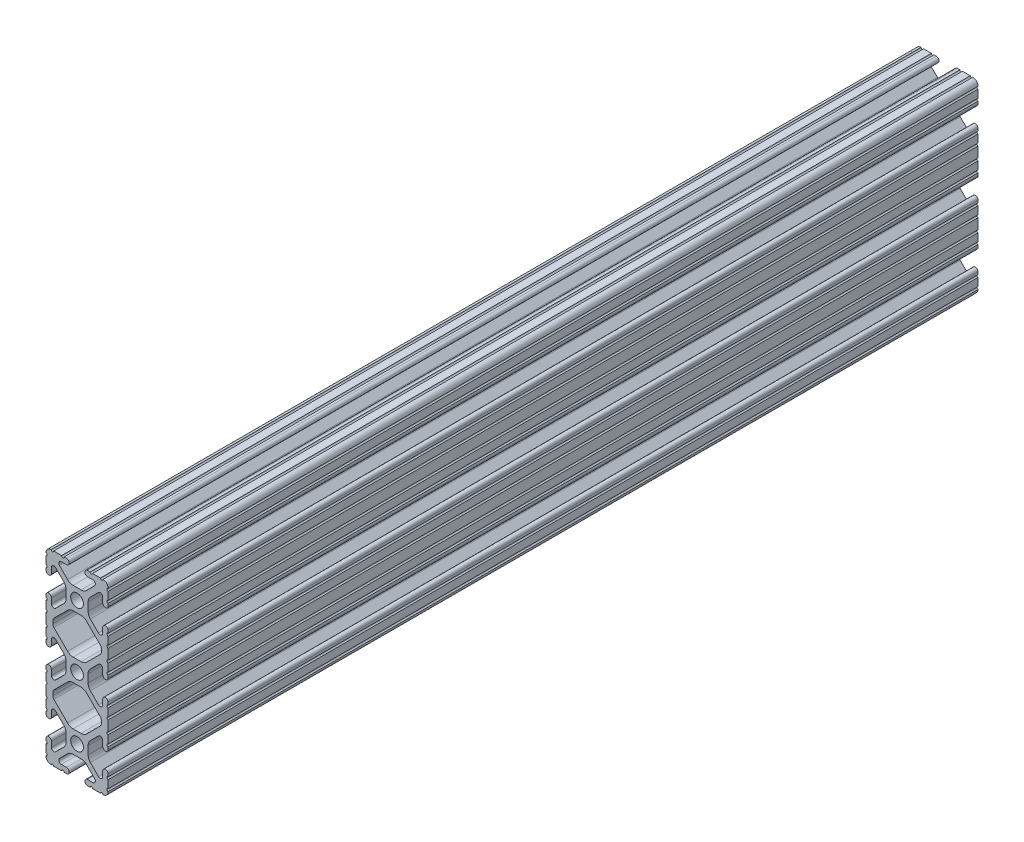
from build123d import *

# Parameters (mm, degrees)
SKETCH1_R           = 2.6035
BOSS_EXTRUDE1_DEPTH = 177.8


with BuildPart() as part:
    # Sketch1 → Boss-Extrude1 (new body, symmetric)
    with BuildSketch(Plane.XY):
        with BuildLine():
            Line((-12.7, 34.9504), (-12.7, 31.7246))
            ThreePointArc((-12.7, 31.7246), (-12.192, 31.2166), (-12.7, 30.7086))
            Line((-12.7, 30.7086), (-12.7, 29.702307889))
            ThreePointArc((-12.7, 29.702307889), (-11.5951, 28.597407889), (-10.4902, 29.702307889))
            Line((-10.4902, 29.702307889), (-10.4902, 31.874794456))
            ThreePointArc((-10.4902, 31.874794456), (-9.863006367, 32.813456061), (-8.75577951, 32.593214945))
            Line((-8.75577951, 32.593214945), (-5.43843597, 29.275871405))
            ThreePointArc((-5.43843597, 29.275871405), (-4.750182484, 28.245827272), (-4.5085, 27.030807374))
            Line((-4.5085, 27.030807374), (-4.5085, 23.769192626))
            ThreePointArc((-4.5085, 23.769192626), (-4.750182484, 22.554172728), (-5.43843597, 21.524128595))
            Line((-5.43843597, 21.524128595), (-8.75577951, 18.206785055))
            ThreePointArc((-8.75577951, 18.206785055), (-9.863006367, 17.986543939), (-10.4902, 18.925205544))
            Line((-10.4902, 18.925205544), (-10.4902, 21.097692111))
            ThreePointArc((-10.4902, 21.097692111), (-11.5951, 22.202592111), (-12.7, 21.097692111))
            Line((-12.7, 21.097692111), (-12.7, 20.0914))
            ThreePointArc((-12.7, 20.0914), (-12.192, 19.5834), (-12.7, 19.0754))
            Line((-12.7, 19.0754), (-12.7, 15.8496))
            ThreePointArc((-12.7, 15.8496), (-12.192, 15.3416), (-12.7, 14.8336))
            Line((-12.7, 14.8336), (-12.7, 10.5664))
            ThreePointArc((-12.7, 10.5664), (-12.192, 10.0584), (-12.7, 9.5504))
            Line((-12.7, 9.5504), (-12.7, 6.3246))
            ThreePointArc((-12.7, 6.3246), (-12.192000017, 5.8166), (-12.7, 5.3086))
            Line((-12.7, 5.3086), (-12.7, 4.302307889))
            ThreePointArc((-12.7, 4.302307889), (-11.5951, 3.197407889), (-10.4902, 4.302307889))
            Line((-10.4902, 4.302307889), (-10.4902, 6.474794456))
            ThreePointArc((-10.4902, 6.474794456), (-9.863006367, 7.413456061), (-8.75577951, 7.193214945))
            Line((-8.75577951, 7.193214945), (-5.43843597, 3.875871405))
            ThreePointArc((-5.43843597, 3.875871405), (-4.750182484, 2.845827272), (-4.5085, 1.630807374))
            Line((-4.5085, 1.630807374), (-4.5085, -1.630807374))
            ThreePointArc((-4.5085, -1.630807374), (-4.750182484, -2.845827272), (-5.43843597, -3.875871405))
            Line((-5.43843597, -3.875871405), (-8.75577951, -7.193214945))
            ThreePointArc((-8.75577951, -7.193214945), (-9.863006367, -7.413456061), (-10.4902, -6.474794456))
            Line((-10.4902, -6.474794456), (-10.4902, -4.302307889))
            ThreePointArc((-10.4902, -4.302307889), (-11.5951, -3.197407889), (-12.7, -4.302307889))
            Line((-12.7, -4.302307889), (-12.7, -5.3086))
            ThreePointArc((-12.7, -5.3086), (-12.191999983, -5.8166), (-12.7, -6.3246))
            Line((-12.7, -6.3246), (-12.7, -9.5504))
            ThreePointArc((-12.7, -9.5504), (-12.192, -10.0584), (-12.7, -10.5664))
            Line((-12.7, -10.5664), (-12.7, -14.8336))
            ThreePointArc((-12.7, -14.8336), (-12.192, -15.3416), (-12.7, -15.8496))
            Line((-12.7, -15.8496), (-12.7, -19.0754))
            ThreePointArc((-12.7, -19.0754), (-12.192, -19.5834), (-12.7, -20.0914))
            Line((-12.7, -20.0914), (-12.7, -21.097692111))
            ThreePointArc((-12.7, -21.097692111), (-11.5951, -22.202592111), (-10.4902, -21.097692111))
            Line((-10.4902, -21.097692111), (-10.4902, -18.925205544))
            ThreePointArc((-10.4902, -18.925205544), (-9.863006367, -17.986543939), (-8.75577951, -18.206785055))
            Line((-8.75577951, -18.206785055), (-5.43843597, -21.524128595))
            ThreePointArc((-5.43843597, -21.524128595), (-4.750182484, -22.554172728), (-4.5085, -23.769192626))
            Line((-4.5085, -23.769192626), (-4.5085, -27.030807374))
            ThreePointArc((-4.5085, -27.030807374), (-4.750182484, -28.245827272), (-5.43843597, -29.275871405))
            Line((-5.43843597, -29.275871405), (-8.75577951, -32.593214945))
            ThreePointArc((-8.75577951, -32.593214945), (-9.863006367, -32.813456061), (-10.4902, -31.874794456))
            Line((-10.4902, -31.874794456), (-10.4902, -29.702307889))
            ThreePointArc((-10.4902, -29.702307889), (-11.5951, -28.597407889), (-12.7, -29.702307889))
            Line((-12.7, -29.702307889), (-12.7, -30.7086))
            ThreePointArc((-12.7, -30.7086), (-12.192, -31.2166), (-12.7, -31.7246))
            Line((-12.7, -31.7246), (-12.7, -34.9504))
            ThreePointArc((-12.7, -34.9504), (-12.192, -35.4584), (-12.7, -35.9664))
            ThreePointArc((-12.7, -35.9664), (-12.082677406, -37.482677406), (-10.5664, -38.1))
            ThreePointArc((-10.5664, -38.1), (-10.0584, -37.592), (-9.5504, -38.1))
            Line((-9.5504, -38.1), (-6.3246, -38.1))
            ThreePointArc((-6.3246, -38.1), (-5.816599996, -37.592000017), (-5.3086, -38.100000008))
            Line((-5.3086, -38.100000008), (-4.302307889, -38.100000008))
            ThreePointArc((-4.302307889, -38.100000008), (-3.197407889, -36.995100008), (-4.302307889, -35.890200008))
            Line((-4.302307889, -35.890200008), (-6.474794456, -35.890200008))
            ThreePointArc((-6.474794456, -35.890200008), (-7.413456061, -35.263006376), (-7.193214945, -34.155779519))
            Line((-7.193214945, -34.155779519), (-3.875871405, -30.838435978))
            ThreePointArc((-3.875871405, -30.838435978), (-2.845827272, -30.150182493), (-1.630807374, -29.908500008))
            Line((-1.630807374, -29.908500008), (1.630807374, -29.908500008))
            ThreePointArc((1.630807374, -29.908500008), (2.845827272, -30.150182493), (3.875871405, -30.838435978))
            Line((3.875871405, -30.838435978), (7.193214945, -34.155779519))
            ThreePointArc((7.193214945, -34.155779519), (7.413456061, -35.263006376), (6.474794456, -35.890200008))
            Line((6.474794456, -35.890200008), (4.302307889, -35.890200008))
            ThreePointArc((4.302307889, -35.890200008), (3.197407889, -36.995100008), (4.302307889, -38.100000008))
            Line((4.302307889, -38.100000008), (5.3086, -38.100000008))
            ThreePointArc((5.3086, -38.100000008), (5.8166, -37.591999992), (6.3246, -38.100000008))
            Line((6.3246, -38.100000008), (9.5504, -38.100000008))
            ThreePointArc((9.5504, -38.100000008), (10.0584, -37.592000008), (10.5664, -38.100000008))
            ThreePointArc((10.5664, -38.100000008), (12.082677406, -37.482677414), (12.7, -35.966400008))
            ThreePointArc((12.7, -35.966400008), (12.192, -35.458400008), (12.7, -34.950400008))
            Line((12.7, -34.950400008), (12.7, -31.724600008))
            ThreePointArc((12.7, -31.724600008), (12.192, -31.216600008), (12.7, -30.708600008))
            Line((12.7, -30.708600008), (12.7, -29.702307926))
            ThreePointArc((12.7, -29.702307926), (11.5951, -28.597407926), (10.4902, -29.702307926))
            Line((10.4902, -29.702307926), (10.4902, -31.874794464))
            ThreePointArc((10.4902, -31.874794464), (9.863006367, -32.813456069), (8.75577951, -32.593214954))
            Line((8.75577951, -32.593214954), (5.43843597, -29.275871413))
            ThreePointArc((5.43843597, -29.275871413), (4.750182484, -28.245827281), (4.5085, -27.030807383))
            Line((4.5085, -27.030807383), (4.5085, -23.769192634))
            ThreePointArc((4.5085, -23.769192634), (4.750182484, -22.554172736), (5.43843597, -21.524128604))
            Line((5.43843597, -21.524128604), (8.75577951, -18.206785063))
            ThreePointArc((8.75577951, -18.206785063), (9.863006367, -17.986543948), (10.4902, -18.925205553))
            Line((10.4902, -18.925205553), (10.4902, -21.097692067))
            ThreePointArc((10.4902, -21.097692067), (11.5951, -22.202592067), (12.7, -21.097692067))
            Line((12.7, -21.097692067), (12.7, -20.091400008))
            ThreePointArc((12.7, -20.091400008), (12.192, -19.583400008), (12.7, -19.075400008))
            Line((12.7, -19.075400008), (12.7, -15.849600008))
            ThreePointArc((12.7, -15.849600008), (12.192, -15.341600008), (12.7, -14.833600008))
            Line((12.7, -14.833600008), (12.7, -10.566400008))
            ThreePointArc((12.7, -10.566400008), (12.192, -10.058400008), (12.7, -9.550400008))
            Line((12.7, -9.550400008), (12.7, -6.324600008))
            ThreePointArc((12.7, -6.324600008), (12.192000017, -5.816600008), (12.7, -5.308600008))
            Line((12.7, -5.308600008), (12.7, -4.302307897))
            ThreePointArc((12.7, -4.302307897), (11.5951, -3.197407897), (10.4902, -4.302307897))
            Line((10.4902, -4.302307897), (10.4902, -6.474794464))
            ThreePointArc((10.4902, -6.474794464), (9.863006367, -7.413456069), (8.75577951, -7.193214954))
            Line((8.75577951, -7.193214954), (5.43843597, -3.875871413))
            ThreePointArc((5.43843597, -3.875871413), (4.750182484, -2.845827281), (4.5085, -1.630807383))
            Line((4.5085, -1.630807383), (4.5085, 1.630807366))
            ThreePointArc((4.5085, 1.630807366), (4.750182484, 2.845827264), (5.43843597, 3.875871396))
            Line((5.43843597, 3.875871396), (8.75577951, 7.193214937))
            ThreePointArc((8.75577951, 7.193214937), (9.863006367, 7.413456052), (10.4902, 6.474794447))
            Line((10.4902, 6.474794447), (10.4902, 4.302307881))
            ThreePointArc((10.4902, 4.302307881), (11.5951, 3.197407881), (12.7, 4.302307881))
            Line((12.7, 4.302307881), (12.7, 5.308599992))
            ThreePointArc((12.7, 5.308599992), (12.191999983, 5.816599992), (12.7, 6.324599992))
            Line((12.7, 6.324599992), (12.7, 9.550399992))
            ThreePointArc((12.7, 9.550399992), (12.192, 10.058399992), (12.7, 10.566399992))
            Line((12.7, 10.566399992), (12.7, 14.833599992))
            ThreePointArc((12.7, 14.833599992), (12.192, 15.341599992), (12.7, 15.849599992))
            Line((12.7, 15.849599992), (12.7, 19.075399992))
            ThreePointArc((12.7, 19.075399992), (12.192, 19.583399992), (12.7, 20.091399992))
            Line((12.7, 20.091399992), (12.7, 21.097692074))
            ThreePointArc((12.7, 21.097692074), (11.5951, 22.202592074), (10.4902, 21.097692074))
            Line((10.4902, 21.097692074), (10.4902, 18.925205536))
            ThreePointArc((10.4902, 18.925205536), (9.863006367, 17.986543931), (8.75577951, 18.206785046))
            Line((8.75577951, 18.206785046), (5.43843597, 21.524128587))
            ThreePointArc((5.43843597, 21.524128587), (4.750182484, 22.554172719), (4.5085, 23.769192617))
            Line((4.5085, 23.769192617), (4.5085, 27.030807366))
            ThreePointArc((4.5085, 27.030807366), (4.750182484, 28.245827264), (5.43843597, 29.275871396))
            Line((5.43843597, 29.275871396), (8.75577951, 32.593214937))
            ThreePointArc((8.75577951, 32.593214937), (9.863006367, 32.813456052), (10.4902, 31.874794447))
            Line((10.4902, 31.874794447), (10.4902, 29.702307881))
            ThreePointArc((10.4902, 29.702307881), (11.5951, 28.597407881), (12.7, 29.702307881))
            Line((12.7, 29.702307881), (12.7, 30.708599992))
            ThreePointArc((12.7, 30.708599992), (12.192, 31.216599992), (12.7, 31.724599992))
            Line((12.7, 31.724599992), (12.7, 34.9504))
            ThreePointArc((12.7, 34.9504), (12.192, 35.4584), (12.7, 35.9664))
            ThreePointArc((12.7, 35.9664), (12.082677406, 37.482677406), (10.5664, 38.1))
            ThreePointArc((10.5664, 38.1), (10.0584, 37.592), (9.5504, 38.1))
            Line((9.5504, 38.1), (6.3246, 38.1))
            ThreePointArc((6.3246, 38.1), (5.8166, 37.591999983), (5.3086, 38.1))
            Line((5.3086, 38.1), (4.302307889, 38.1))
            ThreePointArc((4.302307889, 38.1), (3.197407889, 36.9951), (4.302307889, 35.8902))
            Line((4.302307889, 35.8902), (6.474794456, 35.8902))
            ThreePointArc((6.474794456, 35.8902), (7.413456061, 35.263006367), (7.193214945, 34.15577951))
            Line((7.193214945, 34.15577951), (3.875871405, 30.83843597))
            ThreePointArc((3.875871405, 30.83843597), (2.845827272, 30.150182484), (1.630807374, 29.9085))
            Line((1.630807374, 29.9085), (-1.630807374, 29.9085))
            ThreePointArc((-1.630807374, 29.9085), (-2.845827272, 30.150182484), (-3.875871405, 30.83843597))
            Line((-3.875871405, 30.83843597), (-7.193214945, 34.15577951))
            ThreePointArc((-7.193214945, 34.15577951), (-7.413456061, 35.263006367), (-6.474794456, 35.8902))
            Line((-6.474794456, 35.8902), (-4.302307889, 35.8902))
            ThreePointArc((-4.302307889, 35.8902), (-3.197407889, 36.9951), (-4.302307889, 38.1))
            Line((-4.302307889, 38.1), (-5.3086, 38.1))
            ThreePointArc((-5.3086, 38.1), (-5.8166, 37.592000017), (-6.3246, 38.1))
            Line((-6.3246, 38.1), (-9.5504, 38.1))
            ThreePointArc((-9.5504, 38.1), (-10.0584, 37.592), (-10.5664, 38.1))
            ThreePointArc((-10.5664, 38.1), (-12.082677406, 37.482677406), (-12.7, 35.9664))
            ThreePointArc((-12.7, 35.9664), (-12.192, 35.4584), (-12.7, 34.9504))
        make_face()
        with Locations((0, -25.4)):
            Circle(SKETCH1_R, mode=Mode.SUBTRACT)
        Circle(SKETCH1_R, mode=Mode.SUBTRACT)
        with Locations((0, 25.4)):
            Circle(SKETCH1_R, mode=Mode.SUBTRACT)
        with BuildLine():
            Line((-9.9314, -12.146268083), (-9.9314, -13.253731917))
            ThreePointArc((-9.9314, -13.253731917), (-9.811525488, -13.856381786), (-9.470151759, -14.367283676))
            Line((-9.470151759, -14.367283676), (-3.875871405, -19.96156403))
            ThreePointArc((-3.875871405, -19.96156403), (-2.845827272, -20.649817516), (-1.630807374, -20.8915))
            Line((-1.630807374, -20.8915), (1.630807374, -20.8915))
            ThreePointArc((1.630807374, -20.8915), (2.845827272, -20.649817516), (3.875871405, -19.96156403))
            Line((3.875871405, -19.96156403), (9.470151759, -14.367283676))
            ThreePointArc((9.470151759, -14.367283676), (9.811525488, -13.856381786), (9.9314, -13.253731917))
            Line((9.9314, -13.253731917), (9.9314, -12.146268083))
            ThreePointArc((9.9314, -12.146268083), (9.811525488, -11.543618214), (9.470151759, -11.032716324))
            Line((9.470151759, -11.032716324), (3.875871405, -5.43843597))
            ThreePointArc((3.875871405, -5.43843597), (2.845827272, -4.750182484), (1.630807374, -4.5085))
            Line((1.630807374, -4.5085), (-1.630807374, -4.5085))
            ThreePointArc((-1.630807374, -4.5085), (-2.845827272, -4.750182484), (-3.875871405, -5.43843597))
            Line((-3.875871405, -5.43843597), (-9.470151759, -11.032716324))
            ThreePointArc((-9.470151759, -11.032716324), (-9.811525488, -11.543618214), (-9.9314, -12.146268083))
        make_face(mode=Mode.SUBTRACT)
        with BuildLine():
            Line((-9.9314, 13.253731917), (-9.9314, 12.146268083))
            ThreePointArc((-9.9314, 12.146268083), (-9.811525488, 11.543618214), (-9.470151759, 11.032716324))
            Line((-9.470151759, 11.032716324), (-3.875871405, 5.43843597))
            ThreePointArc((-3.875871405, 5.43843597), (-2.845827272, 4.750182484), (-1.630807374, 4.5085))
            Line((-1.630807374, 4.5085), (1.630807374, 4.5085))
            ThreePointArc((1.630807374, 4.5085), (2.845827272, 4.750182484), (3.875871405, 5.43843597))
            Line((3.875871405, 5.43843597), (9.470151759, 11.032716324))
            ThreePointArc((9.470151759, 11.032716324), (9.811525488, 11.543618214), (9.9314, 12.146268083))
            Line((9.9314, 12.146268083), (9.9314, 13.253731917))
            ThreePointArc((9.9314, 13.253731917), (9.811525488, 13.856381786), (9.470151759, 14.367283676))
            Line((9.470151759, 14.367283676), (3.875871405, 19.96156403))
            ThreePointArc((3.875871405, 19.96156403), (2.845827272, 20.649817516), (1.630807374, 20.8915))
            Line((1.630807374, 20.8915), (-1.630807374, 20.8915))
            ThreePointArc((-1.630807374, 20.8915), (-2.845827272, 20.649817516), (-3.875871405, 19.96156403))
            Line((-3.875871405, 19.96156403), (-9.470151759, 14.367283676))
            ThreePointArc((-9.470151759, 14.367283676), (-9.811525488, 13.856381786), (-9.9314, 13.253731917))
        make_face(mode=Mode.SUBTRACT)
    extrude(amount=BOSS_EXTRUDE1_DEPTH, both=True)


solid = part.part
